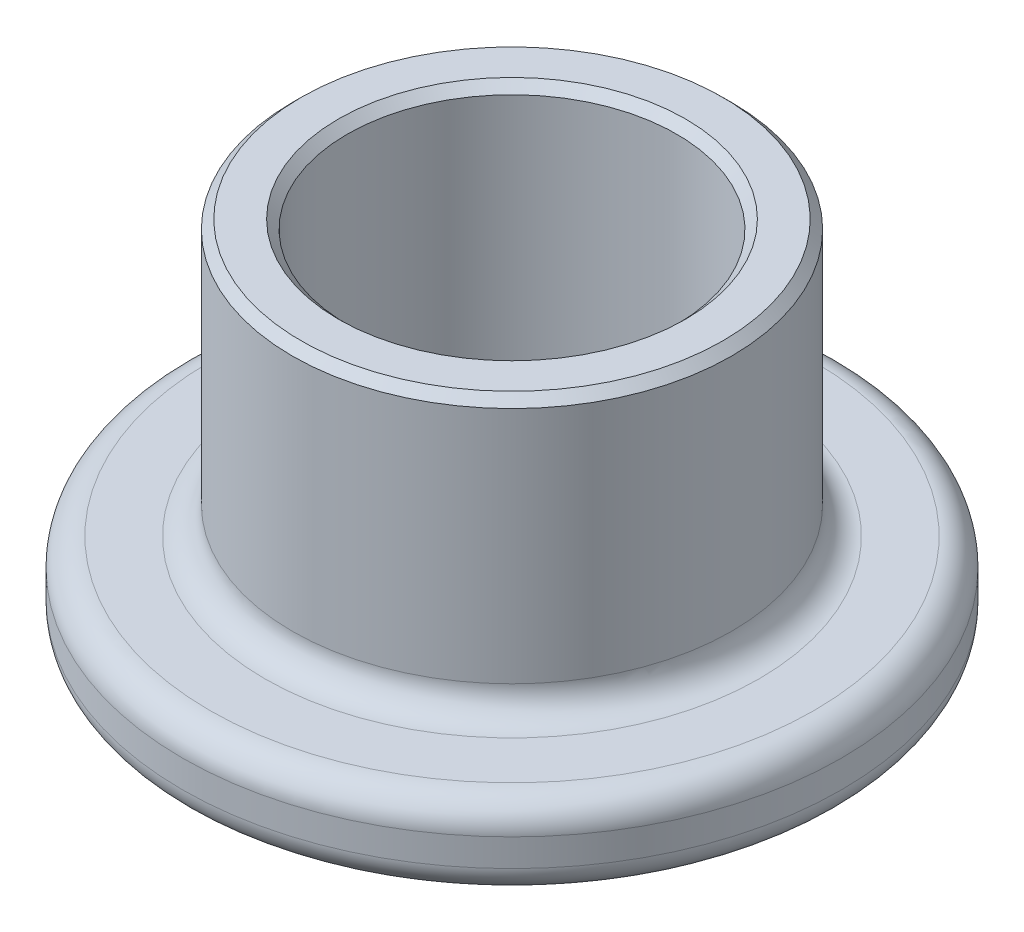
from build123d import *

# Parameters (mm, degrees)
FILLET1_R     = 0.396875
CHAMFER1_SIZE = 0.127


with BuildPart() as part:
    # Sketch1 → Revolve1 (revolve)
    with BuildSketch(Plane.XY):
        Polygon((2.38125, 0), (4.7625, 0), (4.7625, 1.190625), (3.175, 1.190625), (3.175, 5.159375), (2.38125, 5.159375), align=None)
    revolve(axis=Axis((0, 1.896667818, 0), (0, -1, 0)))

    # Fillet1
    fillet1_edges = [part.edges().sort_by_distance(p)[0] for p in [
        (-3.175, 1.190625, 0),
        (-4.7625, 1.190625, 0),
        (-4.7625, 0, 0),
    ]]
    fillet(fillet1_edges, radius=FILLET1_R)

    # Chamfer1
    chamfer1_edges = [part.edges().sort_by_distance(p)[0] for p in [
        (-2.38125, 5.159375, 0),
        (-3.175, 5.159375, 0),
        (-2.38125, 0, 0),
    ]]
    chamfer(chamfer1_edges, length=CHAMFER1_SIZE)


solid = part.part
